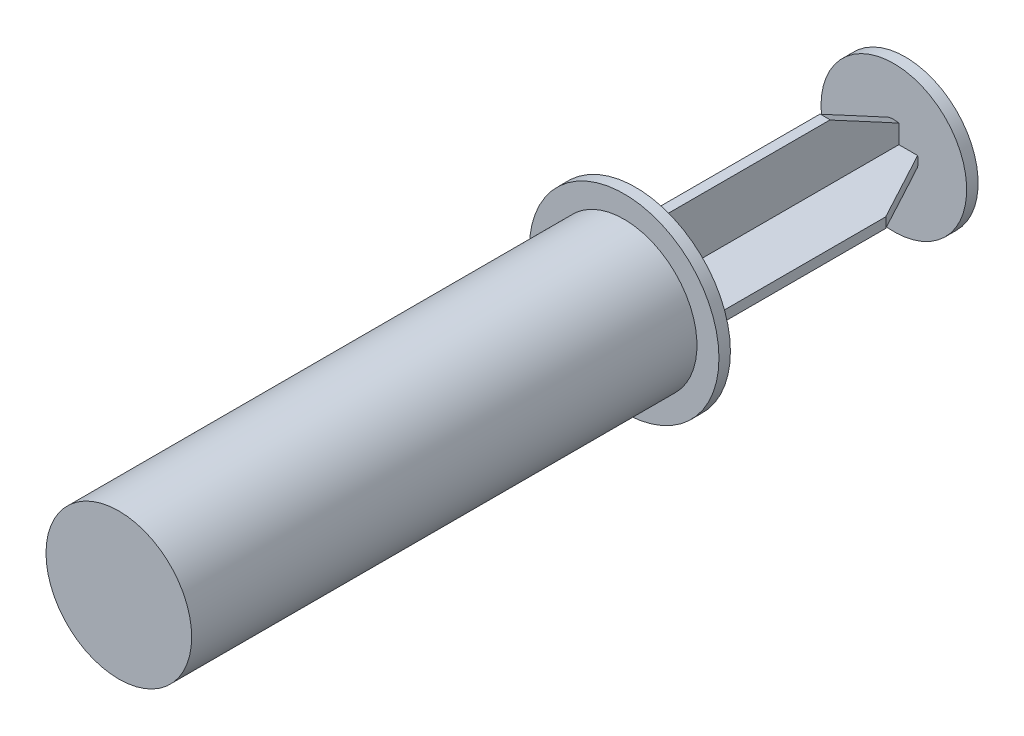
from build123d import *

# Parameters (mm, degrees)
SKETCH1_R           = 15.9
BOSS_EXTRUDE1_DEPTH = 110.3
SKETCH4_R           = 20.7
BOSS_EXTRUDE4_DEPTH = 2.5
SKETCH2_W           = 2.2
SKETCH2_H           = 12.2
SKETCH2_H_2         = 2.2
SKETCH2_W_2         = 12.2
BOSS_EXTRUDE2_DEPTH = 56.375
SKETCH3_R           = 15.9
BOSS_EXTRUDE3_DEPTH = 2.5
SKETCH5_W           = 15
SKETCH5_H           = 1.651179813


with BuildPart() as part:
    # Sketch1 → Boss-Extrude1 (new body)
    with BuildSketch(Plane.XY):
        Circle(SKETCH1_R)
    extrude(amount=BOSS_EXTRUDE1_DEPTH)

    # Sketch4 → Boss-Extrude4 (add)
    with BuildSketch(Plane(origin=(0, 0, 0), x_dir=(-1, 0, 0), z_dir=(0, 0, -1))):
        Circle(SKETCH4_R)
    extrude(amount=BOSS_EXTRUDE4_DEPTH)

    # Sketch2 → Boss-Extrude2 (add)
    with BuildSketch(Plane(origin=(0, 0, -2.5), x_dir=(-1, 0, 0), z_dir=(0, 0, -1))):
        with Locations((0, 7.2)):
            Rectangle(SKETCH2_W, SKETCH2_H)
        Rectangle(SKETCH2_W, SKETCH2_H_2)
        with Locations((0, -7.2)):
            Rectangle(SKETCH2_W, SKETCH2_H)
        with Locations((7.2, 0)):
            Rectangle(SKETCH2_W_2, SKETCH2_H_2)
        with Locations((-7.2, 0)):
            Rectangle(SKETCH2_W_2, SKETCH2_H_2)
    extrude(amount=BOSS_EXTRUDE2_DEPTH)

    # Sketch3 → Boss-Extrude3 (add)
    with BuildSketch(Plane(origin=(0, 0, -58.875), x_dir=(-1, 0, 0), z_dir=(0, 0, -1))):
        Circle(SKETCH3_R)
    extrude(amount=BOSS_EXTRUDE3_DEPTH)

    # Sketch5 → Cut-Revolve4 (revolve, cut)
    with BuildSketch(Plane(origin=(0, 0, 0), x_dir=(0, 0, -1), z_dir=(1, 0, 0))):
        with Locations((51.375, 14.125589907)):
            Rectangle(SKETCH5_W, SKETCH5_H)
        Polygon((58.875, 13.3), (58.875, 5.3), (43.875, 13.3), align=None)
    revolve(axis=Axis((0, 0, 121.7025), (0, 0, -1)), mode=Mode.SUBTRACT)


solid = part.part
